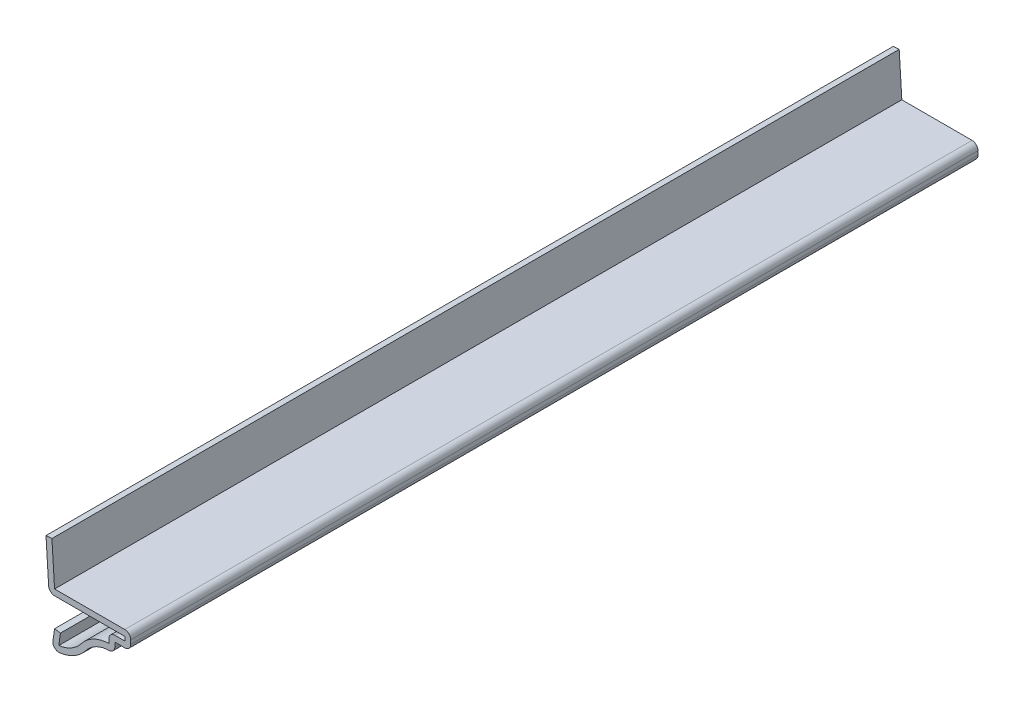
from build123d import *

# Parameters (mm, degrees)
EXTRUDE_THIN1_DEPTH = 127
FILLET1_R           = 0.889


with BuildPart() as part:
    # Sketch1 → Extrude-Thin1 (new body)
    with BuildSketch(Plane.XY):
        with BuildLine():
            Line((0, 14.2875), (0.396875, 7.9375))
            Line((0.396875, 7.9375), (11.811, 7.9375))
            Line((11.811, 7.9375), (11.811, 5.55625))
            Line((11.811, 5.55625), (9.42975, 5.55625))
            Line((9.42975, 5.55625), (9.42975, 3.96875))
            ThreePointArc((9.42975, 3.96875), (7.038283045, 3.743245435), (5.112942469, 2.306920202))
            ThreePointArc((5.112942469, 2.306920202), (2.845206289, 0.513522178), (0, 0))
            Line((0, 0), (0.396875, 2.778125))
            Line((0.396875, 2.778125), (1.2769401, 2.652401414))
            Line((1.2769401, 2.652401414), (1.028787976, 0.915336544))
            ThreePointArc((1.028787976, 0.915336544), (2.912071238, 1.54452561), (4.408676393, 2.849442363))
            ThreePointArc((4.408676393, 2.849442363), (6.237754348, 4.359868554), (8.54075, 4.928308939))
            Line((8.54075, 4.928308939), (8.54075, 6.44525))
            Line((8.54075, 6.44525), (10.922, 6.44525))
            Line((10.922, 6.44525), (10.922, 7.0485))
            Line((10.922, 7.0485), (-0.438297136, 7.0485))
            Line((-0.438297136, 7.0485), (-0.887268742, 14.232045704))
            Line((-0.887268742, 14.232045704), (0, 14.2875))
        make_face()
    extrude(amount=-EXTRUDE_THIN1_DEPTH)

    # Fillet1
    fillet1_edges = [part.edges().sort_by_distance(p)[0] for p in [
        (8.54075, 6.44525, -63.5),
        (-0.438297136, 7.0485, -63.5),
        (11.811, 7.9375, -63.5),
        (11.811, 5.55625, -63.5),
        (9.42975, 3.96875, -63.5),
        (0, 0, -63.5),
    ]]
    fillet(fillet1_edges, radius=FILLET1_R)


solid = part.part
